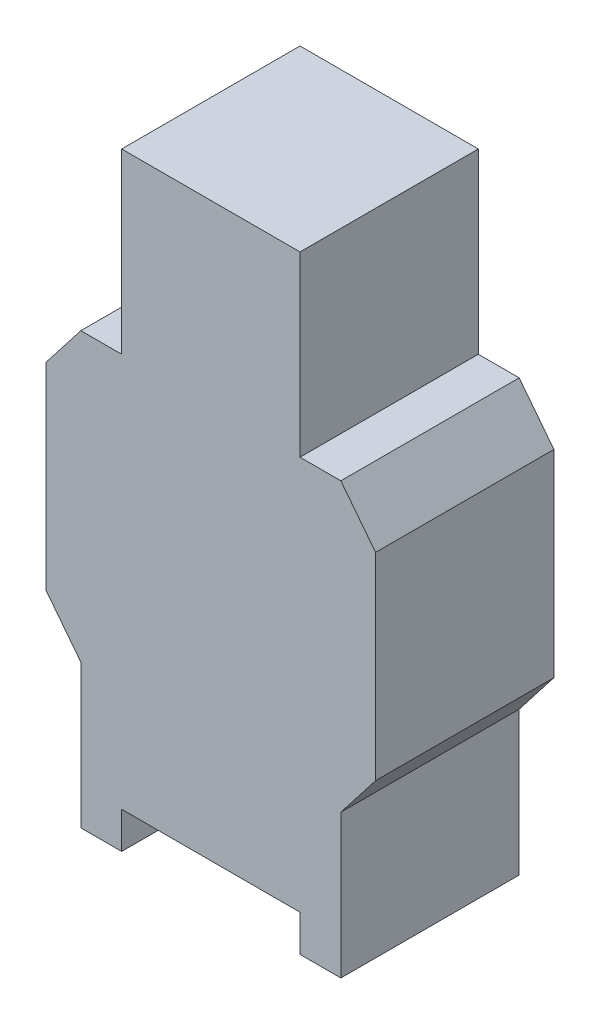
from build123d import *

# Parameters (mm, degrees)
BOSS_EXTRUDE1_DEPTH = 1.524


with BuildPart() as part:
    # Sketch1 → Boss-Extrude1 (new body)
    with BuildSketch(Plane.XY):
        Polygon((1.524, 0.331357602), (1.524, 0.019038457), (1.873085688, 0.019038457), (1.873085688, 1.246196741), (2.169840011, 1.627797902), (2.169840011, 3.317365369), (1.873085688, 3.69896653), (1.524, 3.69896653), (1.524, 5.218451674), (0, 5.218451674), (0, 3.69896653), (-0.349085688, 3.69896653), (-0.645840011, 3.317365369), (-0.645840011, 1.627797902), (-0.349085688, 1.246196741), (-0.349085688, 0.019038457), (0, 0.019038457), (0, 0.331357602), align=None)
    extrude(amount=BOSS_EXTRUDE1_DEPTH)


solid = part.part
